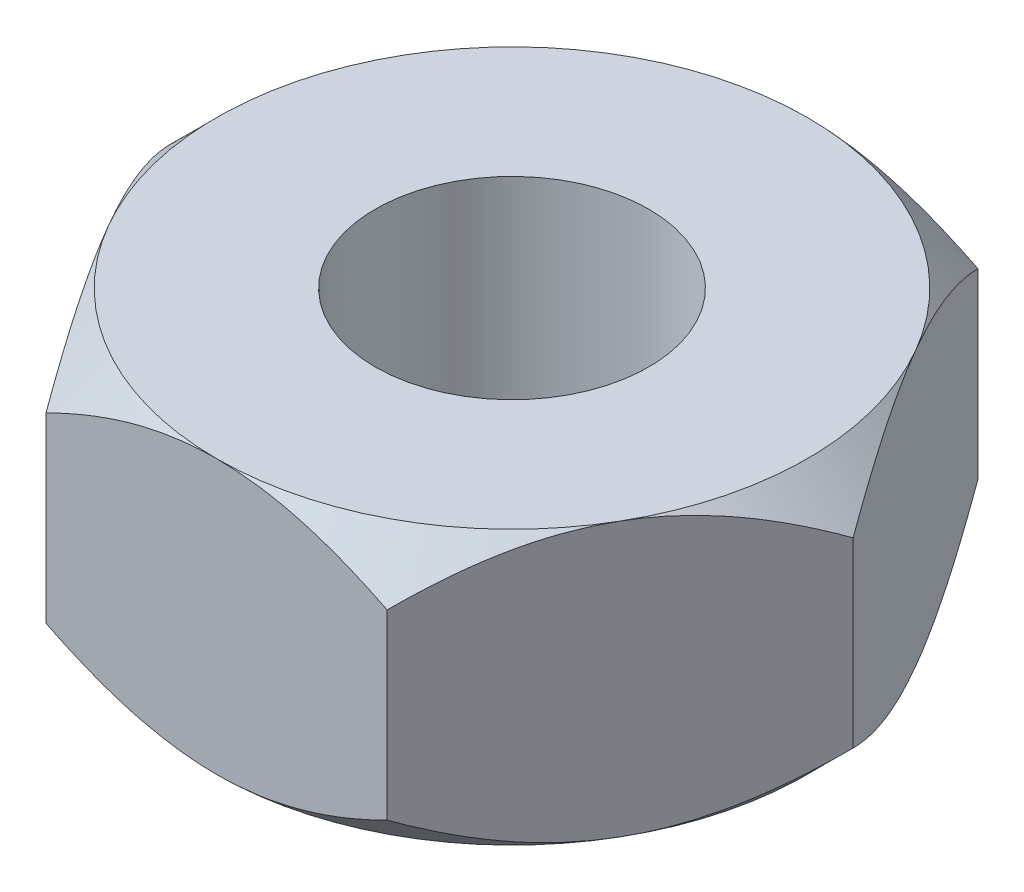
from build123d import *

# Parameters (mm, degrees)
BOSS_EXTRUDE1_DEPTH = 1.25
M3_TAPPED_HOLE1_D   = 2.5
SKETCH4_OUTSIDE_W   = 14.96
SKETCH4_OUTSIDE_H   = 14.124
SKETCH4_OUTSIDE_R   = 2.7
CUT_EXTRUDE1_DEPTH  = 2.5
CUT_EXTRUDE1_TAPER  = 45


with BuildPart() as part:
    # Sketch2 → Boss-Extrude1 (new body, symmetric)
    with BuildSketch(Plane(origin=(0, 0, 0), x_dir=(1, 0, 0), z_dir=(0, 1, 0))):
        Polygon((3.117691454, 0), (1.558845727, 2.7), (-1.558845727, 2.7), (-3.117691454, 0), (-1.558845727, -2.7), (1.558845727, -2.7), align=None)
    extrude(amount=BOSS_EXTRUDE1_DEPTH, both=True)

    # M3 Tapped Hole1 (through all)
    with Locations(Plane.ZX.offset(1.25)):
        with Locations((0, 0)):
            Hole(M3_TAPPED_HOLE1_D / 2)

    # Sketch4 outside → Cut-Extrude1 (cut)
    with BuildSketch(Plane.XZ.offset(1.25)):
        Rectangle(SKETCH4_OUTSIDE_W, SKETCH4_OUTSIDE_H)
        Circle(SKETCH4_OUTSIDE_R, mode=Mode.SUBTRACT)
    cut_extrude1 = extrude(amount=-CUT_EXTRUDE1_DEPTH, taper=CUT_EXTRUDE1_TAPER, mode=Mode.SUBTRACT)

    # Mirror1: Cut-Extrude1 across plane
    add(cut_extrude1.mirror(Plane.ZX), mode=Mode.SUBTRACT)


solid = part.part
